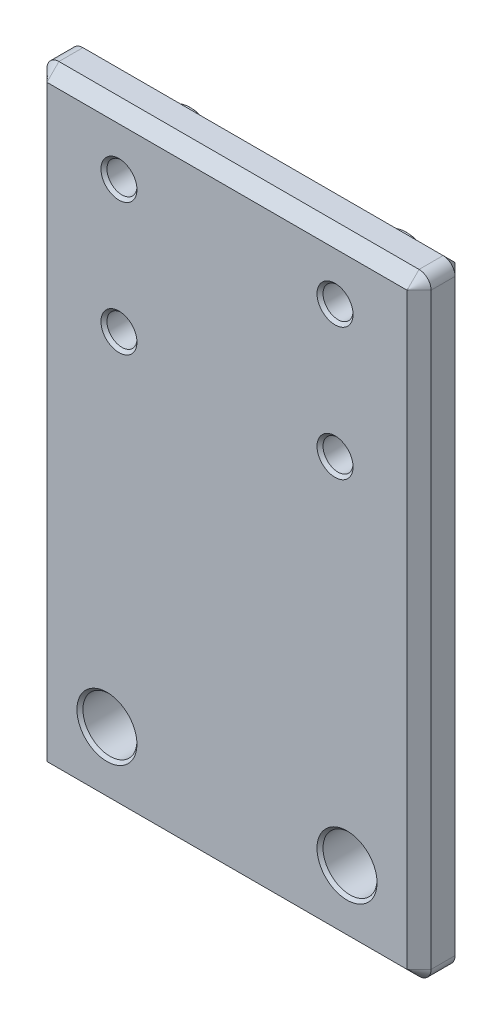
from build123d import *

# Parameters (mm, degrees)
SKETCH1_W                      = 32
SKETCH1_H                      = 51
BOSS_EXTRUDE1_DEPTH            = 4
SKETCH1_3_R                    = 2.25
BOSS_EXTRUDE2_DEPTH            = 2
F_2_5MM_DOWEL_HOLE1_AT_2_COUNT = 2
F_2_5MM_DOWEL_HOLE1_AT_2_PITCH = 11
F_2_5MM_DOWEL_HOLE1_AT_3_COUNT = 2
F_2_5MM_DOWEL_HOLE1_AT_3_PITCH = 21.09502311
F_2_5MM_DOWEL_HOLE1_AT_4_COUNT = 2
F_2_5MM_DOWEL_HOLE1_AT_4_PITCH = 18
M4_CLEARANCE_HOLE1_AT_2_COUNT  = 2
M4_CLEARANCE_HOLE1_AT_2_PITCH  = 20
FILLET1_R                      = 1
CHAMFER1_SIZE                  = 1
CHAMFER2_SIZE                  = 0.1


with BuildPart() as part:
    # Sketch1 → Boss-Extrude1 (new body)
    with BuildSketch(Plane.XY):
        with Locations((0, -15)):
            Rectangle(SKETCH1_W, SKETCH1_H)
    extrude(amount=BOSS_EXTRUDE1_DEPTH)

    # Sketch1_3 → Boss-Extrude2 (add)
    with BuildSketch(Plane.XY):
        with Locations((-9, 5.5)):
            Circle(SKETCH1_3_R)
        with Locations((-9, -5.5)):
            Circle(SKETCH1_3_R)
        with Locations((9, -5.5)):
            Circle(SKETCH1_3_R)
        with Locations((9, 5.5)):
            Circle(SKETCH1_3_R)
    extrude(amount=-BOSS_EXTRUDE2_DEPTH)

    # Sketch5 → Ø2.5mm Dowel Hole1 (revolve, cut)
    with BuildSketch(Plane(origin=(-9, 5.5, -2), x_dir=(0, 1, 0), z_dir=(1, 0, 0))):
        Polygon((0, 0), (0, 6), (1.5, 6), (1.25, 5.75), (1.25, 0.25), (1.5, 0), align=None)
    f_2_5mm_dowel_hole1 = revolve(axis=Axis((-9, 5.5, -8.35), (0, 0, 1)), mode=Mode.SUBTRACT)

    # Ø2.5mm Dowel Hole1 at 2: Ø2.5mm Dowel Hole1 ×2
    with Locations(*[(0, -i * F_2_5MM_DOWEL_HOLE1_AT_2_PITCH, 0) for i in range(1, F_2_5MM_DOWEL_HOLE1_AT_2_COUNT)]):
        add(f_2_5mm_dowel_hole1, mode=Mode.SUBTRACT)

    # Ø2.5mm Dowel Hole1 at 3: Ø2.5mm Dowel Hole1 ×2
    with Locations(*[Vector(0.8532818336519591, -0.521450009453975, 0) * (i * F_2_5MM_DOWEL_HOLE1_AT_3_PITCH) for i in range(1, F_2_5MM_DOWEL_HOLE1_AT_3_COUNT)]):
        add(f_2_5mm_dowel_hole1, mode=Mode.SUBTRACT)

    # Ø2.5mm Dowel Hole1 at 4: Ø2.5mm Dowel Hole1 ×2
    with Locations(*[(i * F_2_5MM_DOWEL_HOLE1_AT_4_PITCH, 0, 0) for i in range(1, F_2_5MM_DOWEL_HOLE1_AT_4_COUNT)]):
        add(f_2_5mm_dowel_hole1, mode=Mode.SUBTRACT)

    # Sketch8 → M4 Clearance Hole1 (revolve, cut)
    with BuildSketch(Plane(origin=(-10, -34.5, 0), x_dir=(0, 1, 0), z_dir=(1, 0, 0))):
        Polygon((0, 0), (0, 4), (2.5, 4), (2.25, 3.75), (2.25, 0.25), (2.5, 0), align=None)
    m4_clearance_hole1 = revolve(axis=Axis((-10, -34.5, -6.35), (0, 0, 1)), mode=Mode.SUBTRACT)

    # M4 Clearance Hole1 at 2: M4 Clearance Hole1 ×2
    with Locations(*[(i * M4_CLEARANCE_HOLE1_AT_2_PITCH, 0, 0) for i in range(1, M4_CLEARANCE_HOLE1_AT_2_COUNT)]):
        add(m4_clearance_hole1, mode=Mode.SUBTRACT)

    # Fillet1
    fillet1_edges = [part.edges().sort_by_distance(p)[0] for p in [
        (16, 10.5, 2),
        (16, -40.5, 2),
        (-16, -40.5, 2),
        (-16, 10.5, 2),
    ]]
    fillet(fillet1_edges, radius=FILLET1_R)

    # Chamfer1
    chamfer1_edges = [part.edges().sort_by_distance(p)[0] for p in [
        (0, -40.5, 4),
        (-15.707106781, -40.207106781, 4),
        (15.707106781, -40.207106781, 4),
        (-16, -15, 4),
        (16, -15, 4),
        (-15.707106781, 10.207106781, 4),
        (15.707106781, 10.207106781, 4),
        (0, 10.5, 4),
        (0, -40.5, 0),
        (-15.707106781, -40.207106781, 0),
        (15.707106781, -40.207106781, 0),
        (-16, -15, 0),
        (16, -15, 0),
        (-15.707106781, 10.207106781, 0),
        (15.707106781, 10.207106781, 0),
        (0, 10.5, 0),
    ]]
    chamfer(chamfer1_edges, length=CHAMFER1_SIZE)

    # Chamfer2
    chamfer2_edges = [part.edges().sort_by_distance(p)[0] for p in [
        (6.75, -5.5, 0),
        (6.75, -5.5, -2),
        (6.75, 5.5, 0),
        (6.75, 5.5, -2),
        (-11.25, -5.5, 0),
        (-11.25, -5.5, -2),
        (-11.25, 5.5, 0),
        (-11.25, 5.5, -2),
    ]]
    chamfer(chamfer2_edges, length=CHAMFER2_SIZE)


solid = part.part
